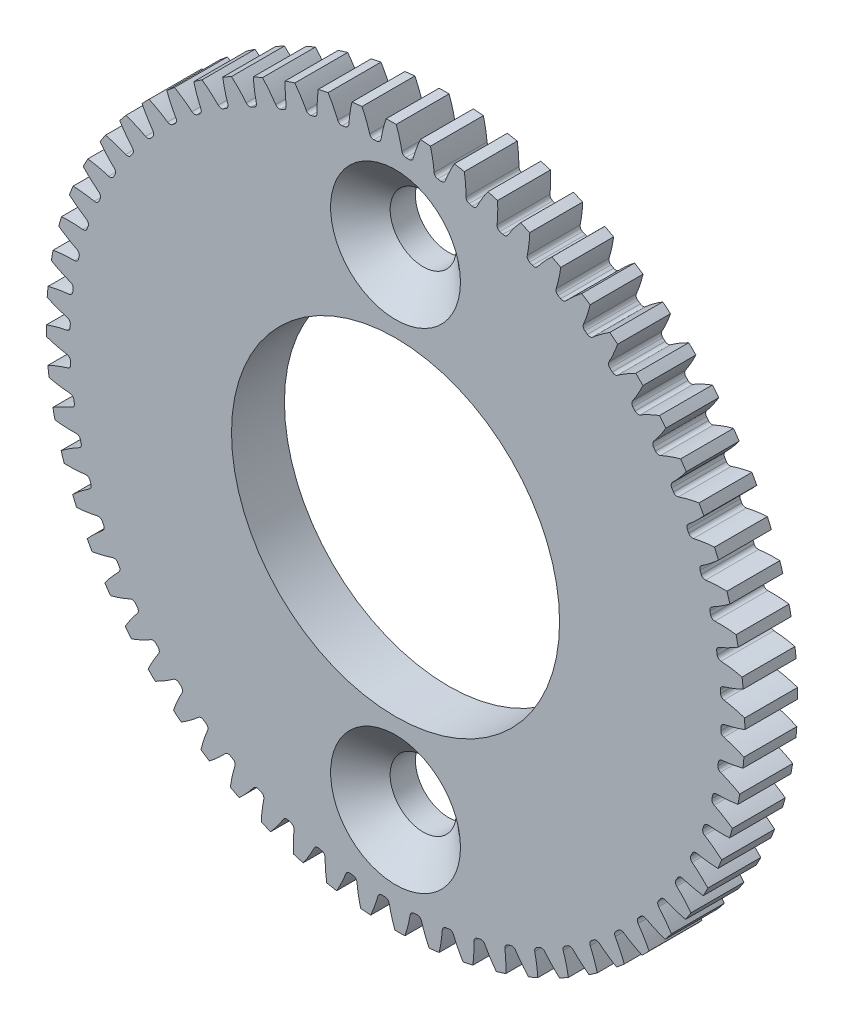
from build123d import *

# Parameters (mm, degrees)
SKETCH3_R         = 41.91
GEARBODY_DEPTH    = 6.35
TOOTHCUT_DEPTH    = 7.35
CIRPATTERN1_COUNT = 64
BOREDIA_R         = 19.685
BOREDIA_R_2       = 3.96875
BORE_DEPTH        = 12.7
CHAMFER2_SIZE     = 3.8227
CHAMFER2_SIZE2    = 3.323022413


with BuildPart() as part:
    # Sketch3 → gearBody (new body)
    with BuildSketch(Plane.XY):
        Circle(SKETCH3_R)
    extrude(amount=GEARBODY_DEPTH)

    # Sketch2 → toothCut (cut, through all)
    with BuildSketch(Plane.XY):
        with BuildLine():
            ThreePointArc((39.031726069, -1.616852216), (39.039033465, -1.429586365), (39.045442404, -1.242287613))
            ThreePointArc((39.045442404, -1.242287613), (39.164057208, -0.934854327), (39.448415717, -0.768346262))
            ThreePointArc((39.448415717, -0.768346262), (45.224956892, 1.592886681), (49.672426571, 5.97054158))
            ThreePointArc((49.672426571, 5.97054158), (49.996453383, -1.830840615), (49.102695574, -9.587628256))
            ThreePointArc((49.102695574, -9.587628256), (44.987322783, -4.89640712), (39.398955649, -2.118997942))
            ThreePointArc((39.398955649, -2.118997942), (39.127537281, -1.932137656), (39.031726069, -1.616852216))
        make_face()
    toothcut = extrude(amount=TOOTHCUT_DEPTH, mode=Mode.SUBTRACT)

    # CirPattern1: toothCut ×64 about axis
    cirpattern1_axis = Axis((0, 0, 0), (0, 0, 1))
    for i in range(1, CIRPATTERN1_COUNT):
        add(toothcut.rotate(cirpattern1_axis, i * 360 / CIRPATTERN1_COUNT), mode=Mode.SUBTRACT)

    # boreDia → bore (cut, symmetric)
    with BuildSketch(Plane.XY):
        Circle(BOREDIA_R)
        with Locations((0, 29.36875)):
            Circle(BOREDIA_R_2)
        with Locations((0, -29.36875)):
            Circle(BOREDIA_R_2)
    extrude(amount=BORE_DEPTH, both=True, mode=Mode.SUBTRACT)

    # Chamfer2
    chamfer2_edges = [part.edges().sort_by_distance(p)[0] for p in [
        (-3.96875, 29.36875, 6.35),
        (-3.96875, -29.36875, 6.35),
    ]]
    chamfer2_side = [part.faces().sort_by_distance(p)[0] for p in [
        (40.373623894, 0.668545042, 6.35),
    ]]
    chamfer(chamfer2_edges, length=CHAMFER2_SIZE, length2=CHAMFER2_SIZE2, reference=chamfer2_side[0])


solid = part.part
